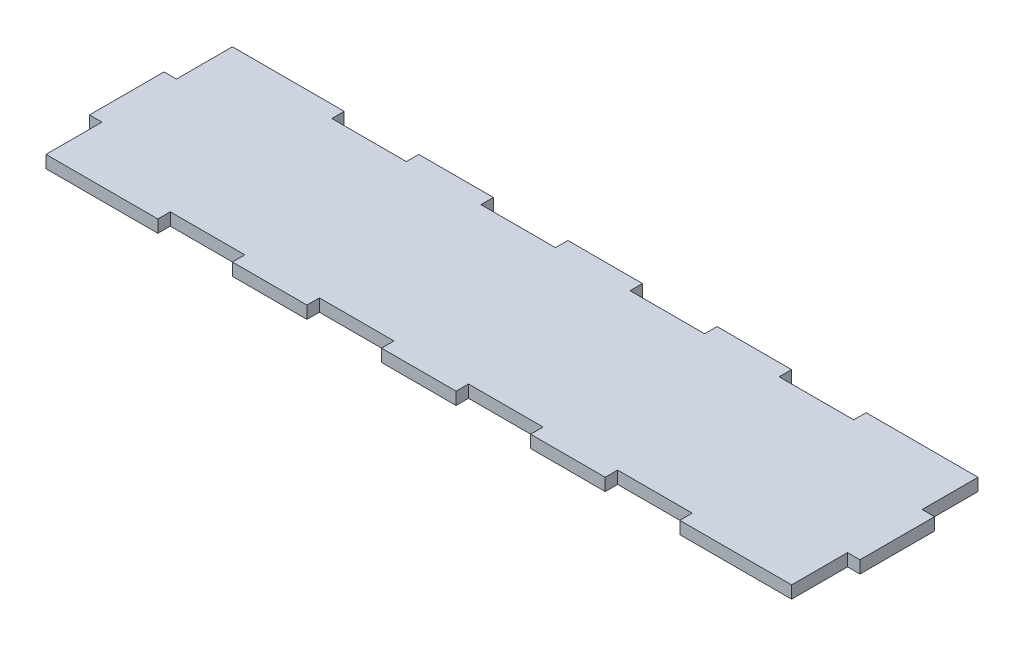
from build123d import *

# Parameters (mm, degrees)
ESQUISSE2_W                     = 381
ESQUISSE2_H                     = 95.25
BOSS_EXTRU_1_DEPTH              = 6.35
ESQUISSE3_W                     = 38.1
ESQUISSE3_H                     = 6.35
BOSS_EXTRU_2_DEPTH              = 6.35
ESQUISSE4_W                     = 38.1
ESQUISSE4_H                     = 6.35
ENL_V_MAT_EXTRU_1_DEPTH         = 6.35
R_P_TITION_LIN_AIRE1_COUNT      = 4
R_P_TITION_LIN_AIRE1_PITCH      = 76.2
R_P_TITION_LIN_AIRE1_COUNT_DIR2 = 2
R_P_TITION_LIN_AIRE1_PITCH_DIR2 = 88.9


with BuildPart() as part:
    # Esquisse2 → Boss.-Extru.1 (new body)
    with BuildSketch(Plane(origin=(0, 0, 0), x_dir=(1, 0, 0), z_dir=(0, 1, 0))):
        Rectangle(ESQUISSE2_W, ESQUISSE2_H)
    extrude(amount=BOSS_EXTRU_1_DEPTH)

    # Esquisse3 → Boss.-Extru.2 (add)
    with BuildSketch(Plane(origin=(190.5, 0, 0), x_dir=(0, 0, -1), z_dir=(1, 0, 0))):
        with Locations((0, 3.175)):
            Rectangle(ESQUISSE3_W, ESQUISSE3_H)
    boss_extru_2 = extrude(amount=BOSS_EXTRU_2_DEPTH)

    # Esquisse4 → Enlèv. mat.-Extru.1 (cut)
    with BuildSketch(Plane(origin=(0, 0, -47.625), x_dir=(-1, 0, 0), z_dir=(0, 0, -1))):
        with Locations((-114.3, 3.175)):
            Rectangle(ESQUISSE4_W, ESQUISSE4_H)
    enl_v_mat_extru_1 = extrude(amount=-ENL_V_MAT_EXTRU_1_DEPTH, mode=Mode.SUBTRACT)

    # Répétition linéaire1: Enl_v. mat.-Extru.1 4 × 2
    with Locations(*[(-i * R_P_TITION_LIN_AIRE1_PITCH, 0, j * R_P_TITION_LIN_AIRE1_PITCH_DIR2) for i in range(R_P_TITION_LIN_AIRE1_COUNT) for j in range(R_P_TITION_LIN_AIRE1_COUNT_DIR2) if (i, j) != (0, 0)]):
        add(enl_v_mat_extru_1, mode=Mode.SUBTRACT)

    # Symétrie1: Boss.-Extru.2 across plane
    add(boss_extru_2.mirror(Plane(origin=(0, 0, 0), x_dir=(0, 0, 1), z_dir=(1, 0, 0))))


solid = part.part
